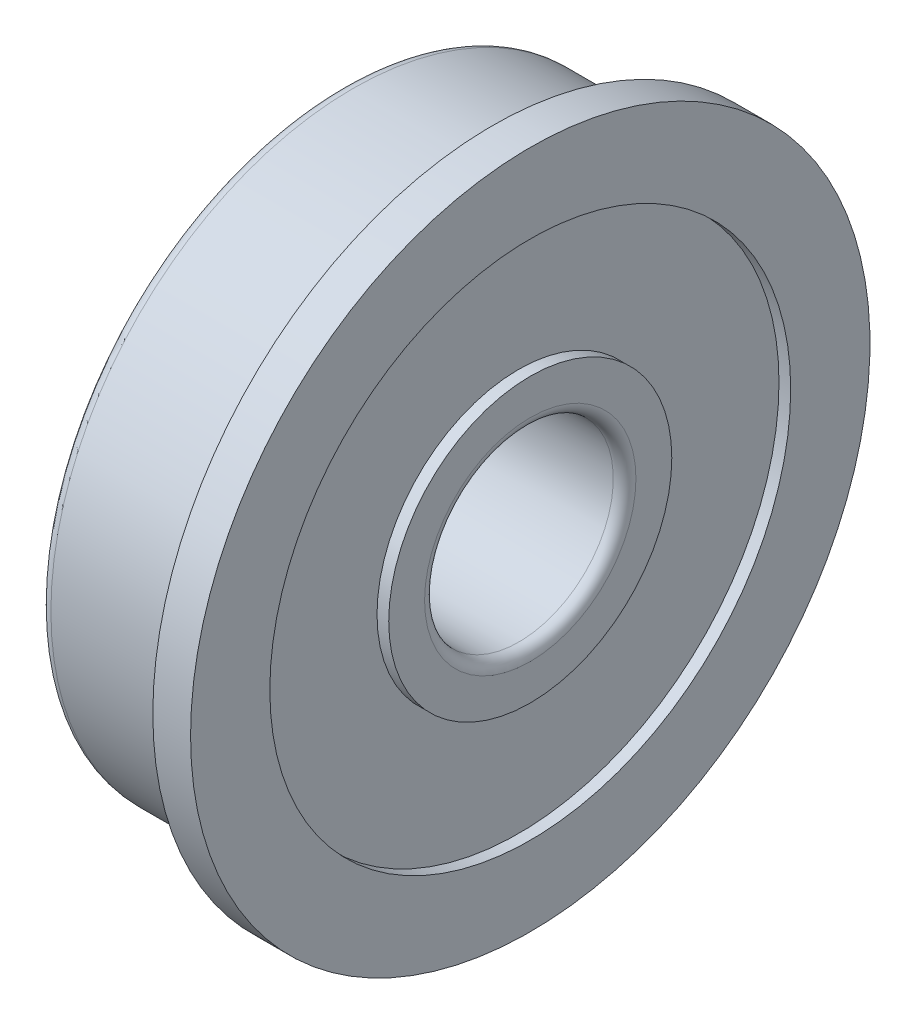
from build123d import *

# Parameters (mm, degrees)
FILLET1_R = 0.3


with BuildPart() as part:
    # Sketch1 → Revolve1 (revolve)
    with BuildSketch(Plane.XY):
        with BuildLine():
            Line((0, 8.2), (0, 9))
            Line((0, 9), (1, 9))
            Line((1, 9), (1, 6.9))
            Line((1, 6.9), (0.69, 6.9))
            Line((0.69, 6.9), (0.69, 3.75))
            Line((0.69, 3.75), (1, 3.75))
            Line((1, 3.75), (1, 2.5))
            Line((1, 2.5), (-4, 2.5))
            Line((-4, 2.5), (-4, 3.75))
            Line((-4, 3.75), (-3.69, 3.75))
            Line((-3.69, 3.75), (-3.69, 6.9))
            Line((-3.69, 6.9), (-4, 6.9))
            Line((-4, 6.9), (-4, 8))
            Line((-4, 8), (-0.2, 8))
            ThreePointArc((-0.2, 8), (0.141421356, 7.858578644), (0, 8.2))
        make_face()
    revolve(axis=Axis((-4, 0, 0), (1, 0, 0)))

    # Fillet1
    fillet1_edges = [part.edges().sort_by_distance(p)[0] for p in [
        (1, -2.5, 0),
        (-4, -2.5, 0),
        (-4, -8, 0),
    ]]
    fillet(fillet1_edges, radius=FILLET1_R)


solid = part.part
